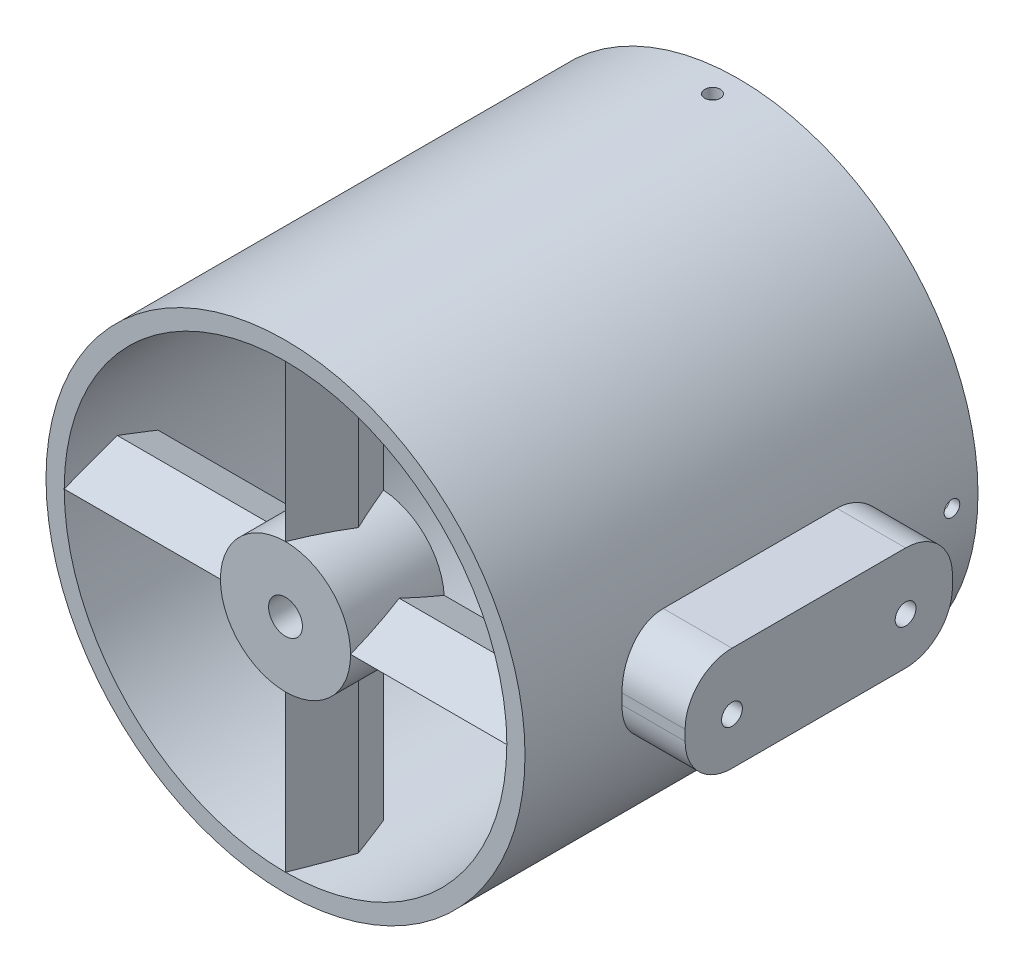
from build123d import *

# Parameters (mm, degrees)
IZIM1_R                           = 12.5
Y_KSEKLIK_EKSTR_ZYON1_DEPTH       = 20
Y_KSEKLIK_EKSTR_ZYON3_DEPTH       = 81
Y_KSEKLIK_EKSTR_ZYON3_DEPTH_BACK  = 93
Y_KSEKLIK_EKSTR_ZYON4_DEPTH       = 95
Y_KSEKLIK_EKSTR_ZYON4_DEPTH_BACK  = 96
IZIM4_R                           = 44.5
IZIM4_R_2                         = 42.5
Y_KSEKLIK_EKSTR_ZYON5_DEPTH       = 20
Y_KSEKLIK_EKSTR_ZYON5_DEPTH_BACK  = 67
KES_EKSTR_ZYON1_DEPTH             = 41.5
KES_EKSTR_ZYON1_DEPTH_BACK        = 46.5
IZIM7_R                           = 46
IZIM7_R_2                         = 44.5
Y_KSEKLIK_EKSTR_ZYON10_DEPTH      = 20
Y_KSEKLIK_EKSTR_ZYON10_DEPTH_BACK = 67
KES_EKSTR_ZYON2_DEPTH             = 42
KES_EKSTR_ZYON2_DEPTH_BACK        = 46
IZIM9_R                           = 1.5
KES_EKSTR_ZYON3_DEPTH             = 58
KES_EKSTR_ZYON3_DEPTH_BACK        = 54
IZIM10_R                          = 1.5
KES_EKSTR_ZYON4_DEPTH             = 60
KES_EKSTR_ZYON4_DEPTH_BACK        = 59
IZIM11_R                          = 109.048897475
IZIM11_R_2                        = 46
KES_EKSTR_ZYON5_DEPTH             = 114
KES_EKSTR_ZYON5_DEPTH_BACK        = 96
IZIM12_R                          = 3.25
KES_EKSTR_ZYON6_DEPTH             = 77
KES_EKSTR_ZYON6_DEPTH_BACK        = 64
IZIM13_R                          = 2
Y_KSEKLIK_EKSTR_ZYON12_DEPTH      = 56
IZIM14_R                          = 42.5
KES_EKSTR_ZYON8_DEPTH             = 75
KES_EKSTR_ZYON8_DEPTH_BACK        = 2
IZIM15_R                          = 2
KES_EKSTR_ZYON9_DEPTH             = 75


with BuildPart() as part:
    # izim1 → Y_kseklik-Ekstr_zyon1 (new body)
    with BuildSketch(Plane.XY):
        with Locations((-2.093293847, -2.497396363)):
            Circle(IZIM1_R)
    extrude(amount=Y_KSEKLIK_EKSTR_ZYON1_DEPTH)

    # izim2 → Y_kseklik-Ekstr_zyon3 (add, two sides)
    with BuildSketch(Plane(origin=(0, 0, 0), x_dir=(0, 0, -1), z_dir=(1, 0, 0))) as y_kseklik_ekstr_zyon3_sk:
        Polygon((-20, -2.497396363), (-10, 1.502603637), (0, -2.497396363), align=None)
        Polygon((-20, -2.497396363), (0, -2.497396363), (-10, -6.497396363), align=None)
    extrude(amount=Y_KSEKLIK_EKSTR_ZYON3_DEPTH)
    extrude(y_kseklik_ekstr_zyon3_sk.sketch, amount=-Y_KSEKLIK_EKSTR_ZYON3_DEPTH_BACK)

    # izim3 → Y_kseklik-Ekstr_zyon4 (add, two sides)
    with BuildSketch(Plane(origin=(0, 0, 0), x_dir=(1, 0, 0), z_dir=(0, 1, 0))) as y_kseklik_ekstr_zyon4_sk:
        Polygon((-6.093293847, -10), (-2.093293847, 0), (-2.093293847, -20), align=None)
        Polygon((1.906706153, -10), (-2.093293847, -20), (-2.093293847, 0), align=None)
    extrude(amount=Y_KSEKLIK_EKSTR_ZYON4_DEPTH)
    extrude(y_kseklik_ekstr_zyon4_sk.sketch, amount=-Y_KSEKLIK_EKSTR_ZYON4_DEPTH_BACK)

    # izim4 → Y_kseklik-Ekstr_zyon5 (add, two sides)
    with BuildSketch(Plane.XY) as y_kseklik_ekstr_zyon5_sk:
        with Locations((-2.093293847, -2.497396363)):
            Circle(IZIM4_R)
        with Locations((-2.093293847, -2.497396363)):
            Circle(IZIM4_R_2, mode=Mode.SUBTRACT)
    extrude(amount=Y_KSEKLIK_EKSTR_ZYON5_DEPTH)
    extrude(y_kseklik_ekstr_zyon5_sk.sketch, amount=-Y_KSEKLIK_EKSTR_ZYON5_DEPTH_BACK)

    # izim5 → Kes-Ekstr_zyon1 (cut, two sides)
    with BuildSketch(Plane(origin=(0, 0, 0), x_dir=(1, 0, 0), z_dir=(0, 1, 0))) as kes_ekstr_zyon1_sk:
        Polygon((-2.093293847, 67), (-6.093293847, 67), (-6.093293847, 54), (1.906706153, 54), (1.906706153, 67), align=None)
    extrude(amount=KES_EKSTR_ZYON1_DEPTH, mode=Mode.SUBTRACT)
    extrude(kes_ekstr_zyon1_sk.sketch, amount=-KES_EKSTR_ZYON1_DEPTH_BACK, mode=Mode.SUBTRACT)

    # izim7 → Y_kseklik-Ekstr_zyon10 (add, two sides)
    with BuildSketch(Plane.XY) as y_kseklik_ekstr_zyon10_sk:
        with Locations((-2.093293847, -2.497396363)):
            Circle(IZIM7_R)
        with Locations((-2.093293847, -2.497396363)):
            Circle(IZIM7_R_2, mode=Mode.SUBTRACT)
    extrude(amount=Y_KSEKLIK_EKSTR_ZYON10_DEPTH)
    extrude(y_kseklik_ekstr_zyon10_sk.sketch, amount=-Y_KSEKLIK_EKSTR_ZYON10_DEPTH_BACK)

    # izim8 → Kes-Ekstr_zyon2 (cut, two sides)
    with BuildSketch(Plane(origin=(0, 0, 0), x_dir=(0, 0, -1), z_dir=(1, 0, 0))) as kes_ekstr_zyon2_sk:
        Polygon((67, -2.497396363), (67, 1.502603637), (54, 1.502603637), (54, -6.497396363), (67, -6.497396363), align=None)
    extrude(amount=KES_EKSTR_ZYON2_DEPTH, mode=Mode.SUBTRACT)
    extrude(kes_ekstr_zyon2_sk.sketch, amount=-KES_EKSTR_ZYON2_DEPTH_BACK, mode=Mode.SUBTRACT)

    # izim9 → Kes-Ekstr_zyon3 (cut, two sides)
    with BuildSketch(Plane(origin=(0, 0, 0), x_dir=(0, 0, -1), z_dir=(1, 0, 0))) as kes_ekstr_zyon3_sk:
        with Locations((62, -2.497396363)):
            Circle(IZIM9_R)
    extrude(amount=KES_EKSTR_ZYON3_DEPTH, mode=Mode.SUBTRACT)
    extrude(kes_ekstr_zyon3_sk.sketch, amount=-KES_EKSTR_ZYON3_DEPTH_BACK, mode=Mode.SUBTRACT)

    # izim10 → Kes-Ekstr_zyon4 (cut, two sides)
    with BuildSketch(Plane(origin=(0, 0, 0), x_dir=(1, 0, 0), z_dir=(0, 1, 0))) as kes_ekstr_zyon4_sk:
        with Locations((-2.093293847, 62)):
            Circle(IZIM10_R)
    extrude(amount=KES_EKSTR_ZYON4_DEPTH, mode=Mode.SUBTRACT)
    extrude(kes_ekstr_zyon4_sk.sketch, amount=-KES_EKSTR_ZYON4_DEPTH_BACK, mode=Mode.SUBTRACT)

    # izim11 → Kes-Ekstr_zyon5 (cut, two sides)
    with BuildSketch(Plane.XY) as kes_ekstr_zyon5_sk:
        with Locations((-2.093293847, -2.497396363)):
            Circle(IZIM11_R)
        with Locations((-2.093293847, -2.497396363)):
            Circle(IZIM11_R_2, mode=Mode.SUBTRACT)
    extrude(amount=KES_EKSTR_ZYON5_DEPTH, mode=Mode.SUBTRACT)
    extrude(kes_ekstr_zyon5_sk.sketch, amount=-KES_EKSTR_ZYON5_DEPTH_BACK, mode=Mode.SUBTRACT)

    # izim12 → Kes-Ekstr_zyon6 (cut, two sides)
    with BuildSketch(Plane.XY) as kes_ekstr_zyon6_sk:
        with Locations((-2.093293847, -2.497396363)):
            Circle(IZIM12_R)
    extrude(amount=KES_EKSTR_ZYON6_DEPTH, mode=Mode.SUBTRACT)
    extrude(kes_ekstr_zyon6_sk.sketch, amount=-KES_EKSTR_ZYON6_DEPTH_BACK, mode=Mode.SUBTRACT)

    # izim13 → Y_kseklik-Ekstr_zyon12 (add)
    with BuildSketch(Plane(origin=(0, 0, 0), x_dir=(0, 0, -1), z_dir=(1, 0, 0))):
        with BuildLine():
            ThreePointArc((7.654129035, -12.497396363), (1.290168004, -9.861357394), (-1.345870965, -3.497396363))
            Line((-1.345870965, -3.497396363), (-1.345870965, -1.497396363))
            ThreePointArc((-1.345870965, -1.497396363), (1.290168004, 4.866564667), (7.654129035, 7.502603637))
            Line((7.654129035, 7.502603637), (41, 7.502603637))
            ThreePointArc((41, 7.502603637), (47.363961031, 4.866564667), (50, -1.497396363))
            Line((50, -1.497396363), (50, -3.497396363))
            ThreePointArc((50, -3.497396363), (47.363961031, -9.861357394), (41, -12.497396363))
            Line((41, -12.497396363), (7.654129035, -12.497396363))
        make_face()
        with Locations((41, -3.497396363)):
            Circle(IZIM13_R, mode=Mode.SUBTRACT)
        with Locations((7.654129035, -3.497396363)):
            Circle(IZIM13_R, mode=Mode.SUBTRACT)
    extrude(amount=Y_KSEKLIK_EKSTR_ZYON12_DEPTH)

    # izim14 → Kes-Ekstr_zyon8 (cut, two sides)
    with BuildSketch(Plane(origin=(0, 0, 0), x_dir=(-1, 0, 0), z_dir=(0, 0, -1))) as kes_ekstr_zyon8_sk:
        with Locations((2.093293847, -2.497396363)):
            Circle(IZIM14_R)
    extrude(amount=KES_EKSTR_ZYON8_DEPTH, mode=Mode.SUBTRACT)
    extrude(kes_ekstr_zyon8_sk.sketch, amount=-KES_EKSTR_ZYON8_DEPTH_BACK, mode=Mode.SUBTRACT)

    # izim15 → Kes-Ekstr_zyon9 (cut)
    with BuildSketch(Plane(origin=(56, 0, 0), x_dir=(0, 0, -1), z_dir=(1, 0, 0))):
        with Locations((7.654129035, -3.497396363)):
            Circle(IZIM15_R)
        with Locations((41, -3.497396363)):
            Circle(IZIM15_R)
    extrude(amount=-KES_EKSTR_ZYON9_DEPTH, mode=Mode.SUBTRACT)


solid = part.part
